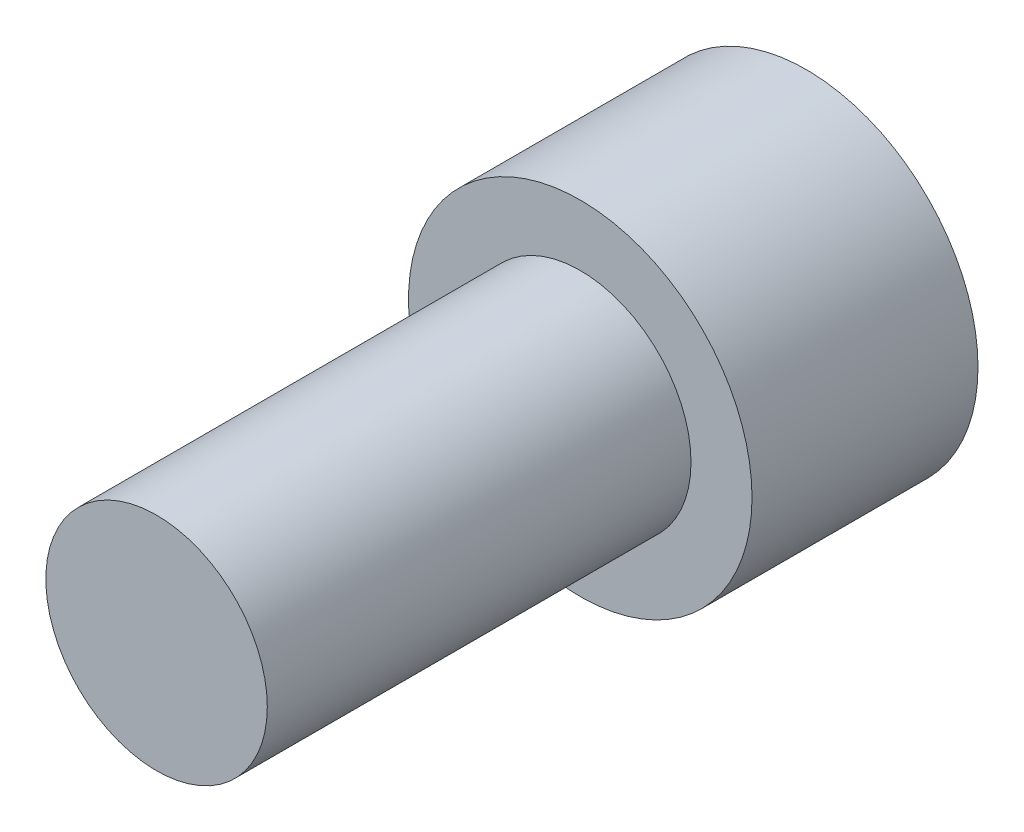
from build123d import *

# Parameters (mm, degrees)
SKETCH1_R         = 3.8608
EXTRUDE1_DEPTH    = 14.605
SKETCH2_OUTSIDE_W = 13.37
SKETCH2_OUTSIDE_H = 13.37
SKETCH2_OUTSIDE_R = 2.4892
EXTRUDE2_DEPTH    = 9.525
EXTRUDE3_DEPTH    = 3.048


with BuildPart() as part:
    # Sketch1 → Extrude1 (new body)
    with BuildSketch(Plane.XY):
        Circle(SKETCH1_R)
    extrude(amount=EXTRUDE1_DEPTH)

    # Sketch2 outside → Extrude2 (cut)
    with BuildSketch(Plane.XY.offset(14.605)):
        Rectangle(SKETCH2_OUTSIDE_W, SKETCH2_OUTSIDE_H)
        Circle(SKETCH2_OUTSIDE_R, mode=Mode.SUBTRACT)
    extrude(amount=-EXTRUDE2_DEPTH, mode=Mode.SUBTRACT)

    # Sketch3 → Extrude3 (cut)
    with BuildSketch(Plane(origin=(0, 0, 0), x_dir=(-1, 0, 0), z_dir=(0, 0, -1))):
        Polygon((0, 2.987683948), (-2.587410198, 1.493841974), (-2.587410198, -1.493841974), (0, -2.987683948), (2.587410198, -1.493841974), (2.587410198, 1.493841974), align=None)
    extrude(amount=-EXTRUDE3_DEPTH, mode=Mode.SUBTRACT)


solid = part.part
